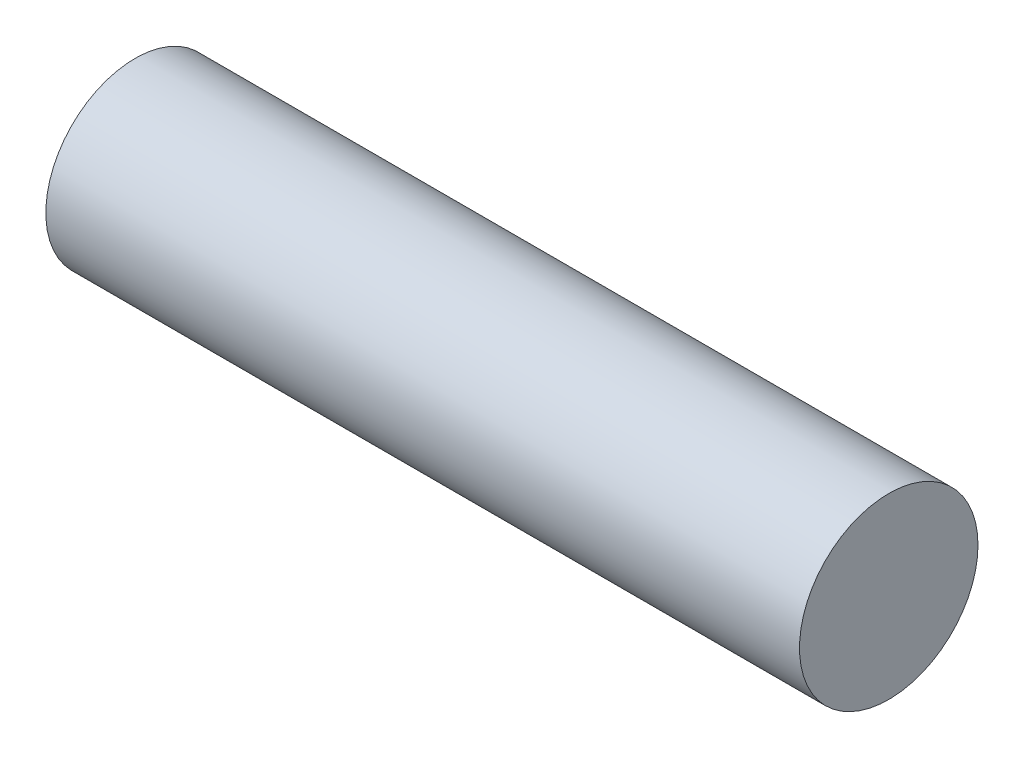
from build123d import *

# Parameters (mm, degrees)
SKETCH1_R           = 9
BOSS_EXTRUDE1_DEPTH = 38


with BuildPart() as part:
    # Sketch1 → Boss-Extrude1 (new body, symmetric)
    with BuildSketch(Plane(origin=(0, 0, 0), x_dir=(0, 0, -1), z_dir=(1, 0, 0))):
        Circle(SKETCH1_R)
    extrude(amount=BOSS_EXTRUDE1_DEPTH, both=True)


solid = part.part
